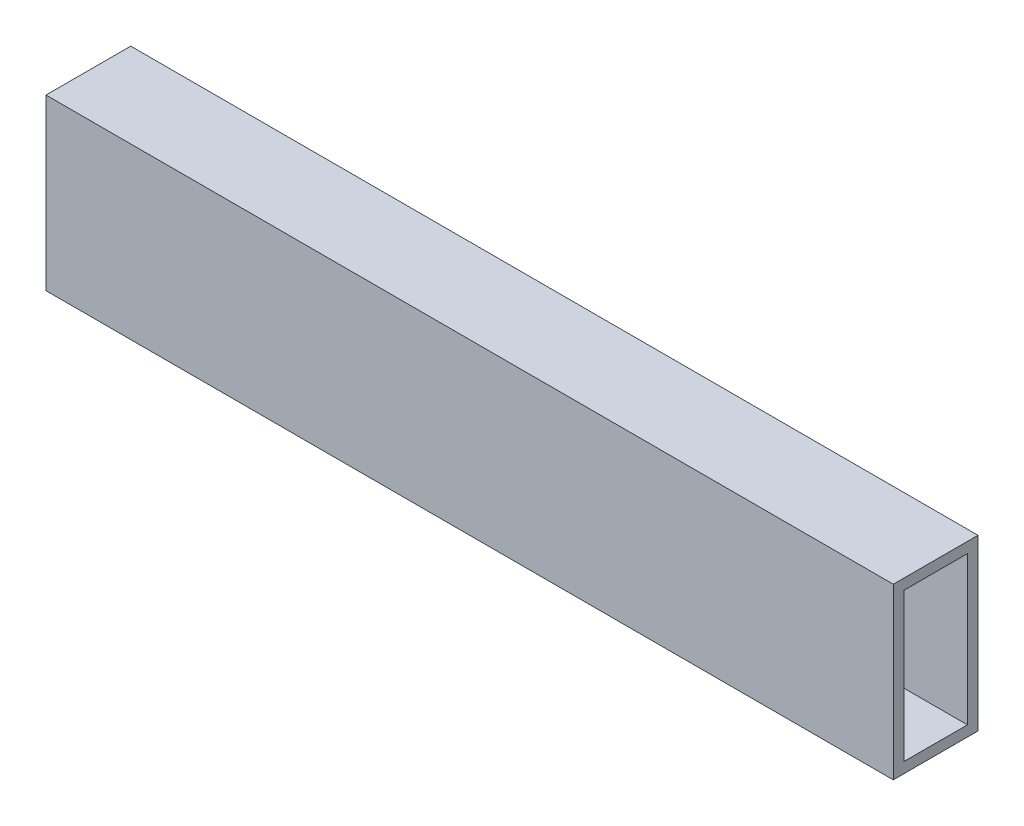
from build123d import *

# Parameters (mm, degrees)
SKETCH1_W           = 25.4
SKETCH1_H           = 50.8
SKETCH1_W_2         = 19.05
SKETCH1_H_2         = 44.45
BOSS_EXTRUDE1_DEPTH = 254


with BuildPart() as part:
    # Sketch1 → Boss-Extrude1 (new body)
    with BuildSketch(Plane(origin=(0, 0, 0), x_dir=(0, 0, -1), z_dir=(1, 0, 0))):
        with Locations((12.7, 25.4)):
            Rectangle(SKETCH1_W, SKETCH1_H)
        with Locations((12.7, 25.4)):
            Rectangle(SKETCH1_W_2, SKETCH1_H_2, mode=Mode.SUBTRACT)
    extrude(amount=BOSS_EXTRUDE1_DEPTH)


solid = part.part
